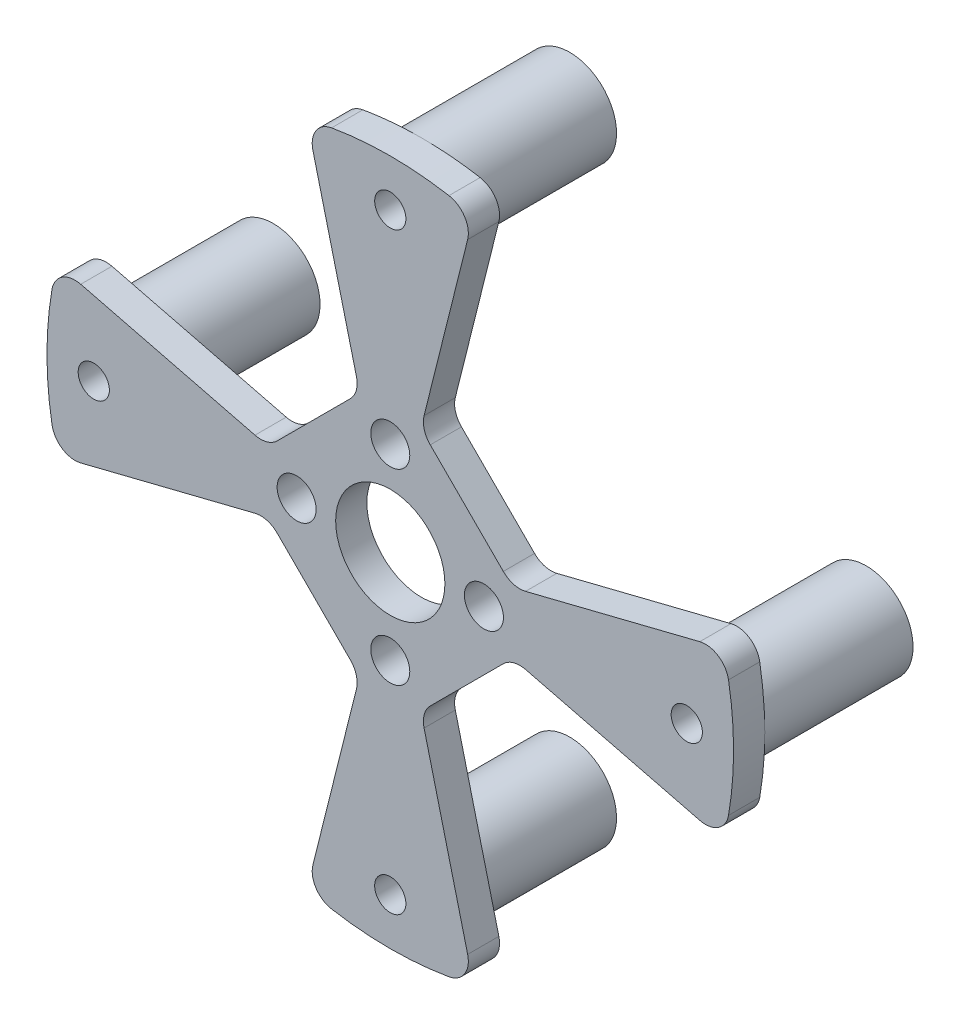
from build123d import *

# Parameters (mm, degrees)
SKETCH_1_R               = 22
EXTRUDE_1_DEPTH          = 2
SKETCH_3_R               = 1.25
CUT_EXTRUDE_1_DEPTH      = 3
SKETCH_4_R               = 3.5
CUT_EXTRUDE_2_DEPTH      = 3
SKETCH_6_R               = 3
EXTRUDE_3_DEPTH          = 9.5
SKETCH_8_R               = 1
CUT_EXTRUDE_4_DEPTH      = 11.5
CUT_EXTRUDE_3_DEPTH      = 6
PATTERN_CIRCULAR_1_COUNT = 4
FILLET_2_R               = 1.5
FILLET_3_R               = 1.5


with BuildPart() as part:
    # 草图1 → 凸台-拉伸1 (new body)
    with BuildSketch(Plane.XY):
        Circle(SKETCH_1_R)
    extrude(amount=EXTRUDE_1_DEPTH)

    # 草图3 → 切除-拉伸1 (cut)
    with BuildSketch(Plane(origin=(0, 0, 0), x_dir=(-1, 0, 0), z_dir=(0, 0, -1))):
        with Locations((6, 0)):
            Circle(SKETCH_3_R)
    cut_extrude_1 = extrude(amount=-CUT_EXTRUDE_1_DEPTH, mode=Mode.SUBTRACT)

    # 草图4 → 切除-拉伸2 (cut)
    with BuildSketch(Plane(origin=(0, 0, 0), x_dir=(-1, 0, 0), z_dir=(0, 0, -1))):
        Circle(SKETCH_4_R)
    extrude(amount=-CUT_EXTRUDE_2_DEPTH, mode=Mode.SUBTRACT)

    # 草图6 → 凸台-拉伸3 (add)
    with BuildSketch(Plane(origin=(0, 0, 0), x_dir=(-1, 0, 0), z_dir=(0, 0, -1))):
        with Locations((0, -19)):
            Circle(SKETCH_6_R)
    extrude_3 = extrude(amount=EXTRUDE_3_DEPTH)

    # 草图8 → 切除-拉伸4 (cut)
    with BuildSketch(Plane(origin=(0, 0, -9.5), x_dir=(-1, 0, 0), z_dir=(0, 0, -1))):
        with Locations((0, -19)):
            Circle(SKETCH_8_R)
    cut_extrude_4 = extrude(amount=-CUT_EXTRUDE_4_DEPTH, mode=Mode.SUBTRACT)

    # 草图7 → 切除-拉伸3 (cut)
    with BuildSketch(Plane(origin=(0, 0, 0), x_dir=(-1, 0, 0), z_dir=(0, 0, -1))):
        Polygon((-1.961261338, 7.845045353), (-7.845045353, 1.961261338), (-30.512752563, 7.628188141), (-7.628188141, 30.512752563), align=None)
    cut_extrude_3 = extrude(amount=-CUT_EXTRUDE_3_DEPTH, mode=Mode.SUBTRACT)

    # 阵列(圆周)1: 切除-拉伸1, 凸台-拉伸3, 切除-拉伸4, 切除-拉伸3 ×4 about axis
    pattern_circular_1_axis = Axis((0, 0, 0), (0, 0, 1))
    for i in range(1, PATTERN_CIRCULAR_1_COUNT):
        add(cut_extrude_1.rotate(pattern_circular_1_axis, i * 360 / PATTERN_CIRCULAR_1_COUNT), mode=Mode.SUBTRACT)
        add(extrude_3.rotate(pattern_circular_1_axis, i * 360 / PATTERN_CIRCULAR_1_COUNT))
        add(cut_extrude_4.rotate(pattern_circular_1_axis, i * 360 / PATTERN_CIRCULAR_1_COUNT), mode=Mode.SUBTRACT)
        add(cut_extrude_3.rotate(pattern_circular_1_axis, i * 360 / PATTERN_CIRCULAR_1_COUNT), mode=Mode.SUBTRACT)

    # 圆角2
    fillet_2_edges = [part.edges().sort_by_distance(p)[0] for p in [
        (-5.335783751, -21.343135003, 1),
        (-21.343135003, -5.335783751, 1),
        (21.343135003, -5.335783751, 1),
        (5.335783751, -21.343135003, 1),
        (5.335783751, 21.343135003, 1),
        (21.343135003, 5.335783751, 1),
        (-21.343135003, 5.335783751, 1),
        (-5.335783751, 21.343135003, 1),
    ]]
    fillet(fillet_2_edges, radius=FILLET_2_R)

    # 圆角3
    fillet_3_edges = [part.edges().sort_by_distance(p)[0] for p in [
        (-7.845045353, -1.961261338, 1),
        (-1.961261338, -7.845045353, 1),
        (1.961261338, -7.845045353, 1),
        (7.845045353, -1.961261338, 1),
        (7.845045353, 1.961261338, 1),
        (1.961261338, 7.845045353, 1),
        (-1.961261338, 7.845045353, 1),
        (-7.845045353, 1.961261338, 1),
    ]]
    fillet(fillet_3_edges, radius=FILLET_3_R)


solid = part.part
